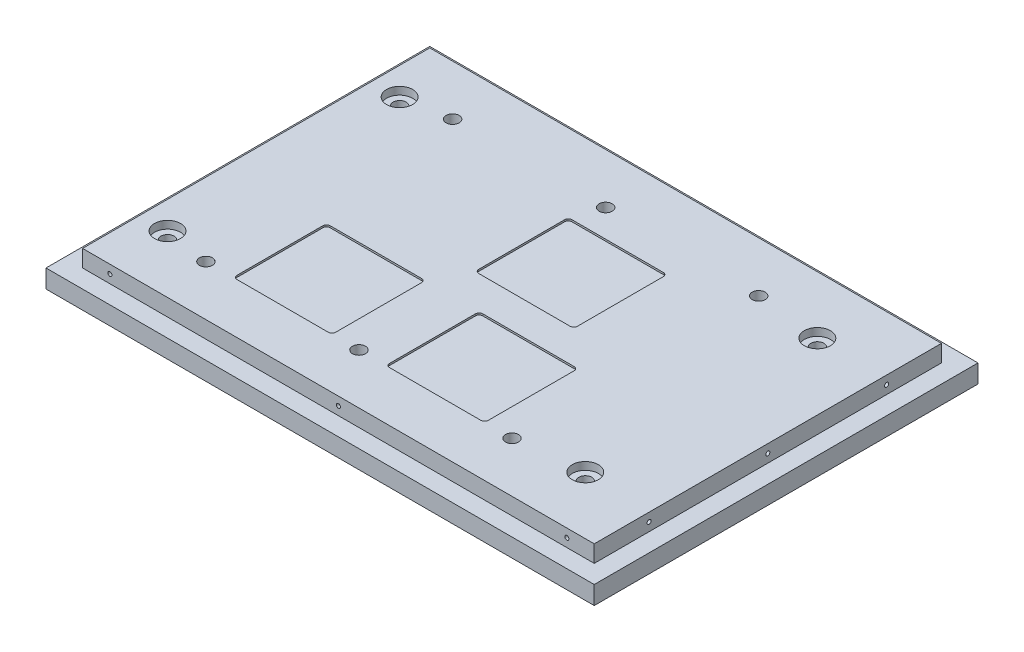
from build123d import *

# Parameters (mm, degrees)
SKETCH1_W                                            = 300
SKETCH1_H                                            = 210
BOSS_EXTRUDE1_DEPTH                                  = 10
SKETCH2_W                                            = 280
SKETCH2_H                                            = 190
BOSS_EXTRUDE2_DEPTH                                  = 9.28
F_1_4_20_CLEARANCE_HOLES_REACH                       = 21.28
SKETCH3_R                                            = 3.57
SKETCH4_R                                            = 7.5
CUT_EXTRUDE2_DEPTH                                   = 10
SKETCH5_R                                            = 1.13
F_4_40_THREADED_HOLES_DEPTH                          = 5
SKETCH6_R                                            = 1.13
F_4_40_THREADED_HOLES_2_DEPTH                        = 5
SKETCH7_R                                            = 1.13
F_4_40_THREADED_HOLES_3_DEPTH                        = 5
SKETCH8_R                                            = 1.13
F_4_40_THREADED_HOLES_4_DEPTH                        = 5
SKETCH11_W                                           = 54
SKETCH11_H                                           = 51
TEC_DEPTH                                            = 1
FILLET1_R                                            = 2
OPTICAL_TABLE_CBORE_FOR_1_4_BINDING_HEAD_D           = 7.14248
OPTICAL_TABLE_CBORE_FOR_1_4_BINDING_HEAD_DEPTH       = 19.28
OPTICAL_TABLE_CBORE_FOR_1_4_BINDING_HEAD_CBORE_D     = 14.2875
OPTICAL_TABLE_CBORE_FOR_1_4_BINDING_HEAD_CBORE_DEPTH = 4.191


with BuildPart() as part:
    # Sketch1 → Boss-Extrude1 (new body)
    with BuildSketch(Plane(origin=(0, 0, 0), x_dir=(1, 0, 0), z_dir=(0, 1, 0))):
        with Locations((-22.864321608, -2.487437186)):
            Rectangle(SKETCH1_W, SKETCH1_H)
    extrude(amount=BOSS_EXTRUDE1_DEPTH)

    # Sketch2 → Boss-Extrude2 (add)
    with BuildSketch(Plane(origin=(0, 10, 0), x_dir=(1, 0, 0), z_dir=(0, 1, 0))):
        with Locations((-22.864321608, -2.487437186)):
            Rectangle(SKETCH2_W, SKETCH2_H)
    extrude(amount=BOSS_EXTRUDE2_DEPTH)

    # Sketch3 → 1/4-20 clearance holes (cut, up to next)
    with BuildSketch(Plane(origin=(0, 19.28, 0), x_dir=(1, 0, 0), z_dir=(0, 1, 0)), mode=Mode.PRIVATE) as f_1_4_20_clearance_holes_sk1:
        with Locations((-122.864321608, 65.012562814)):
            Circle(SKETCH3_R)
    f_1_4_20_clearance_holes_tool1 = extrude(f_1_4_20_clearance_holes_sk1.sketch, amount=-F_1_4_20_CLEARANCE_HOLES_REACH, mode=Mode.PRIVATE) & part.part
    add(f_1_4_20_clearance_holes_tool1.solids().sort_by_distance((-122.864322, 19.28, -65.012563))[0], mode=Mode.SUBTRACT)
    # Sketch3 → 1/4-20 clearance holes (cut, up to next)
    with BuildSketch(Plane(origin=(0, 19.28, 0), x_dir=(1, 0, 0), z_dir=(0, 1, 0)), mode=Mode.PRIVATE) as f_1_4_20_clearance_holes_sk2:
        with Locations((-39.114321608, 65.012562814)):
            Circle(SKETCH3_R)
    f_1_4_20_clearance_holes_tool2 = extrude(f_1_4_20_clearance_holes_sk2.sketch, amount=-F_1_4_20_CLEARANCE_HOLES_REACH, mode=Mode.PRIVATE) & part.part
    add(f_1_4_20_clearance_holes_tool2.solids().sort_by_distance((-39.114322, 19.28, -65.012563))[0], mode=Mode.SUBTRACT)
    # Sketch3 → 1/4-20 clearance holes (cut, up to next)
    with BuildSketch(Plane(origin=(0, 19.28, 0), x_dir=(1, 0, 0), z_dir=(0, 1, 0)), mode=Mode.PRIVATE) as f_1_4_20_clearance_holes_sk3:
        with Locations((44.635678392, 65.012562814)):
            Circle(SKETCH3_R)
    f_1_4_20_clearance_holes_tool3 = extrude(f_1_4_20_clearance_holes_sk3.sketch, amount=-F_1_4_20_CLEARANCE_HOLES_REACH, mode=Mode.PRIVATE) & part.part
    add(f_1_4_20_clearance_holes_tool3.solids().sort_by_distance((44.635678, 19.28, -65.012563))[0], mode=Mode.SUBTRACT)
    # Sketch3 → 1/4-20 clearance holes (cut, up to next)
    with BuildSketch(Plane(origin=(0, 19.28, 0), x_dir=(1, 0, 0), z_dir=(0, 1, 0)), mode=Mode.PRIVATE) as f_1_4_20_clearance_holes_sk4:
        with Locations((44.635678392, -69.987437186)):
            Circle(SKETCH3_R)
    f_1_4_20_clearance_holes_tool4 = extrude(f_1_4_20_clearance_holes_sk4.sketch, amount=-F_1_4_20_CLEARANCE_HOLES_REACH, mode=Mode.PRIVATE) & part.part
    add(f_1_4_20_clearance_holes_tool4.solids().sort_by_distance((44.635678, 19.28, 69.987437))[0], mode=Mode.SUBTRACT)
    # Sketch3 → 1/4-20 clearance holes (cut, up to next)
    with BuildSketch(Plane(origin=(0, 19.28, 0), x_dir=(1, 0, 0), z_dir=(0, 1, 0)), mode=Mode.PRIVATE) as f_1_4_20_clearance_holes_sk5:
        with Locations((-39.114321608, -69.987437186)):
            Circle(SKETCH3_R)
    f_1_4_20_clearance_holes_tool5 = extrude(f_1_4_20_clearance_holes_sk5.sketch, amount=-F_1_4_20_CLEARANCE_HOLES_REACH, mode=Mode.PRIVATE) & part.part
    add(f_1_4_20_clearance_holes_tool5.solids().sort_by_distance((-39.114322, 19.28, 69.987437))[0], mode=Mode.SUBTRACT)
    # Sketch3 → 1/4-20 clearance holes (cut, up to next)
    with BuildSketch(Plane(origin=(0, 19.28, 0), x_dir=(1, 0, 0), z_dir=(0, 1, 0)), mode=Mode.PRIVATE) as f_1_4_20_clearance_holes_sk6:
        with Locations((-122.864321608, -69.987437186)):
            Circle(SKETCH3_R)
    f_1_4_20_clearance_holes_tool6 = extrude(f_1_4_20_clearance_holes_sk6.sketch, amount=-F_1_4_20_CLEARANCE_HOLES_REACH, mode=Mode.PRIVATE) & part.part
    add(f_1_4_20_clearance_holes_tool6.solids().sort_by_distance((-122.864322, 19.28, 69.987437))[0], mode=Mode.SUBTRACT)

    # Sketch4 → Cut-Extrude2 (cut)
    with BuildSketch(Plane.XZ):
        with Locations((-122.864321608, 69.987437186)):
            Circle(SKETCH4_R)
        with Locations((-39.114321608, 69.987437186)):
            Circle(SKETCH4_R)
        with Locations((44.635678392, 69.987437186)):
            Circle(SKETCH4_R)
        with Locations((44.635678392, -65.012562814)):
            Circle(SKETCH4_R)
        with Locations((-39.114321608, -65.012562814)):
            Circle(SKETCH4_R)
        with Locations((-122.864321608, -65.012562814)):
            Circle(SKETCH4_R)
    extrude(amount=-CUT_EXTRUDE2_DEPTH, mode=Mode.SUBTRACT)

    # Sketch5 → 4-40 threaded holes (cut)
    with BuildSketch(Plane.XY.offset(97.487437186)):
        with Locations((-147.864321608, 14.64)):
            Circle(SKETCH5_R)
        with Locations((-22.864321608, 14.64)):
            Circle(SKETCH5_R)
        with Locations((102.135678392, 14.64)):
            Circle(SKETCH5_R)
    extrude(amount=-F_4_40_THREADED_HOLES_DEPTH, mode=Mode.SUBTRACT)

    # Sketch6 → 4-40 threaded holes 2 (cut)
    with BuildSketch(Plane(origin=(0, 0, -92.512562814), x_dir=(-1, 0, 0), z_dir=(0, 0, -1))):
        with Locations((-102.135678392, 14.64)):
            Circle(SKETCH6_R)
        with Locations((22.864321608, 14.64)):
            Circle(SKETCH6_R)
        with Locations((147.864321608, 14.64)):
            Circle(SKETCH6_R)
    extrude(amount=-F_4_40_THREADED_HOLES_2_DEPTH, mode=Mode.SUBTRACT)

    # Sketch7 → 4-40 threaded holes 3 (cut)
    with BuildSketch(Plane.ZY.offset(162.864321608)):
        with Locations((-62.512562814, 14.64)):
            Circle(SKETCH7_R)
        with Locations((2.487437186, 14.64)):
            Circle(SKETCH7_R)
        with Locations((67.487437186, 14.64)):
            Circle(SKETCH7_R)
    extrude(amount=-F_4_40_THREADED_HOLES_3_DEPTH, mode=Mode.SUBTRACT)

    # Sketch8 → 4-40 threaded holes 4 (cut)
    with BuildSketch(Plane(origin=(117.135678392, 0, 0), x_dir=(0, 0, -1), z_dir=(1, 0, 0))):
        with Locations((-67.487437186, 14.64)):
            Circle(SKETCH8_R)
        with Locations((-2.487437186, 14.64)):
            Circle(SKETCH8_R)
        with Locations((62.512562814, 14.64)):
            Circle(SKETCH8_R)
    extrude(amount=-F_4_40_THREADED_HOLES_4_DEPTH, mode=Mode.SUBTRACT)

    # Sketch11 → TEC (cut)
    with BuildSketch(Plane(origin=(0, 19.28, 0), x_dir=(1, 0, 0), z_dir=(0, 1, 0))):
        with Locations((-17.563304852, 24.512562814)):
            Rectangle(SKETCH11_W, SKETCH11_H)
        with Locations((-80.864321608, -44.487437186)):
            Rectangle(SKETCH11_W, SKETCH11_H)
        with Locations((2.635678392, -44.487437186)):
            Rectangle(SKETCH11_W, SKETCH11_H)
    extrude(amount=-TEC_DEPTH, mode=Mode.SUBTRACT)

    # Fillet1
    fillet1_edges = [part.edges().sort_by_distance(p)[0] for p in [
        (9.436695148, 18.78, -50.012562814),
        (9.436695148, 18.78, 0.987437186),
        (-44.563304852, 18.78, 0.987437186),
        (-44.563304852, 18.78, -50.012562814),
        (-53.864321608, 18.78, 69.987437186),
        (-107.864321608, 18.78, 69.987437186),
        (-107.864321608, 18.78, 18.987437186),
        (-53.864321608, 18.78, 18.987437186),
        (29.635678392, 18.78, 69.987437186),
        (-24.364321608, 18.78, 69.987437186),
        (-24.364321608, 18.78, 18.987437186),
        (29.635678392, 18.78, 18.987437186),
    ]]
    fillet(fillet1_edges, radius=FILLET1_R)

    # optical table CBORE for 1/4 Binding Head Machine Screw1
    with Locations(Plane(origin=(0, 19.28, 0), x_dir=(1, 0, 0), z_dir=(0, 1, 0))):
        with Locations((-147.864321608, 61.012562814), (-147.864321608, -65.987437186), (80.735678392, -65.987437186), (80.735678392, 61.012562814)):
            CounterBoreHole(OPTICAL_TABLE_CBORE_FOR_1_4_BINDING_HEAD_D / 2, OPTICAL_TABLE_CBORE_FOR_1_4_BINDING_HEAD_CBORE_D / 2, OPTICAL_TABLE_CBORE_FOR_1_4_BINDING_HEAD_CBORE_DEPTH, depth=OPTICAL_TABLE_CBORE_FOR_1_4_BINDING_HEAD_DEPTH)


solid = part.part
